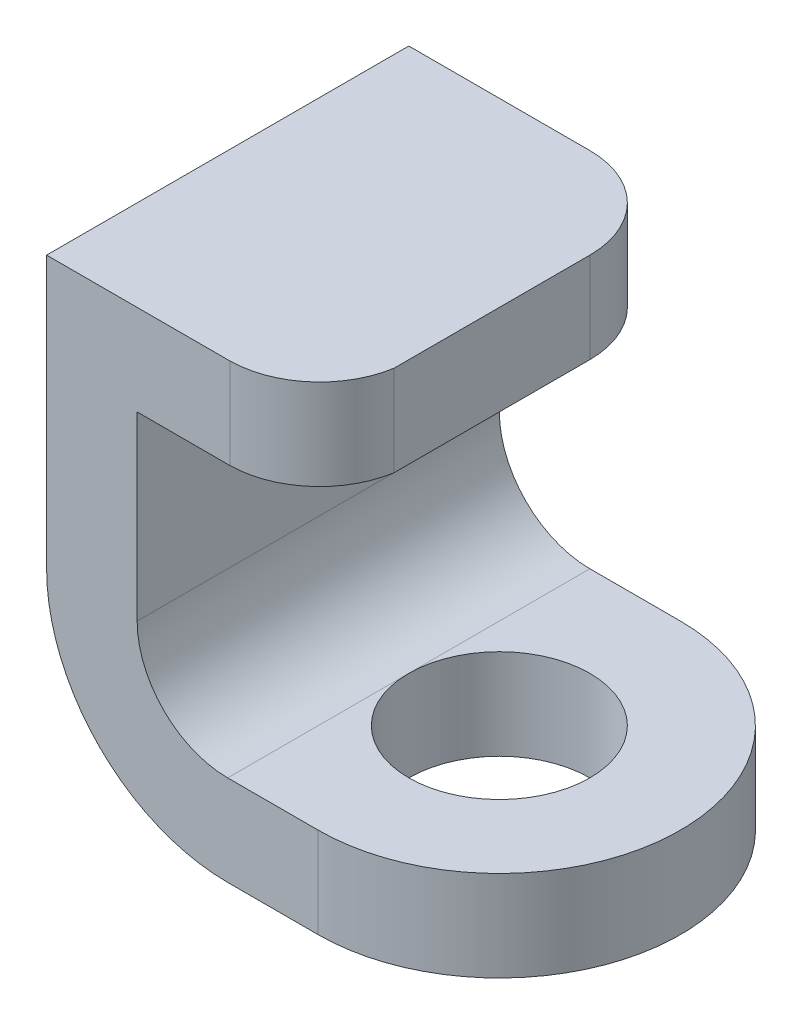
from build123d import *

# Parameters (mm, degrees)
EXTRUDE_THIN1_DEPTH     = 40
CUT_EXTRUDE_THIN1_DEPTH = 10
CUT_EXTRUDE2_DEPTH      = 10


with BuildPart() as part:
    # Sketch1 → Extrude-Thin1 (new body)
    with BuildSketch(Plane.XY):
        with BuildLine():
            Line((0, 0), (-30, 0))
            Line((-30, 0), (-30, -30))
            ThreePointArc((-30, -30), (-24.142135624, -44.142135624), (-10, -50))
            Line((-10, -50), (20, -50))
            Line((20, -50), (20, -40))
            Line((20, -40), (-10, -40))
            ThreePointArc((-10, -40), (-17.071067812, -37.071067812), (-20, -30))
            Line((-20, -30), (-20, -10))
            Line((-20, -10), (0, -10))
            Line((0, -10), (0, 0))
        make_face()
    extrude(amount=EXTRUDE_THIN1_DEPTH)

    # Sketch3 → Cut-Extrude-Thin1 (cut)
    with BuildSketch(Plane(origin=(0, 0, 0), x_dir=(1, 0, 0), z_dir=(0, 1, 0))):
        with BuildLine():
            ThreePointArc((-10, -40), (-3.453740955, -37.676907189), (0, -31.650138477))
            Line((0, -31.650138477), (9.863069314, -33.299339409))
            ThreePointArc((9.863069314, -33.299339409), (2.955587404, -45.352876834), (-10.136930686, -49.999062455))
            Line((-10.136930686, -49.999062455), (-10, -40))
        make_face()
        with BuildLine():
            ThreePointArc((0, -10), (-2.928932188, -2.928932188), (-10, 0))
            Line((-10, 0), (-10, 10))
            ThreePointArc((-10, 10), (4.142135624, 4.142135624), (10, -10))
            Line((10, -10), (0, -10))
        make_face()
    extrude(amount=-CUT_EXTRUDE_THIN1_DEPTH, mode=Mode.SUBTRACT)

    # Sketch10 → Cut-Extrude2 (cut)
    with BuildSketch(Plane(origin=(0, -40, 0), x_dir=(1, 0, 0), z_dir=(0, 1, 0))):
        with BuildLine():
            ThreePointArc((0, 0), (14.142135624, -5.857864376), (20, -20))
            Line((20, -20), (20, 0))
            Line((20, 0), (0, 0))
        make_face()
        with BuildLine():
            ThreePointArc((20, -20), (14.142135624, -34.142135624), (0, -40))
            Line((0, -40), (20, -40))
            Line((20, -40), (20, -20))
        make_face()
        with BuildLine():
            ThreePointArc((0, -10), (-10, -20), (0, -30))
            Line((0, -30), (0, -10))
        make_face()
        with BuildLine():
            Line((0, -10), (0, -30))
            ThreePointArc((0, -30), (7.071067812, -27.071067812), (10, -20))
            ThreePointArc((10, -20), (7.071067812, -12.928932188), (0, -10))
        make_face()
    extrude(amount=-CUT_EXTRUDE2_DEPTH, mode=Mode.SUBTRACT)


solid = part.part
